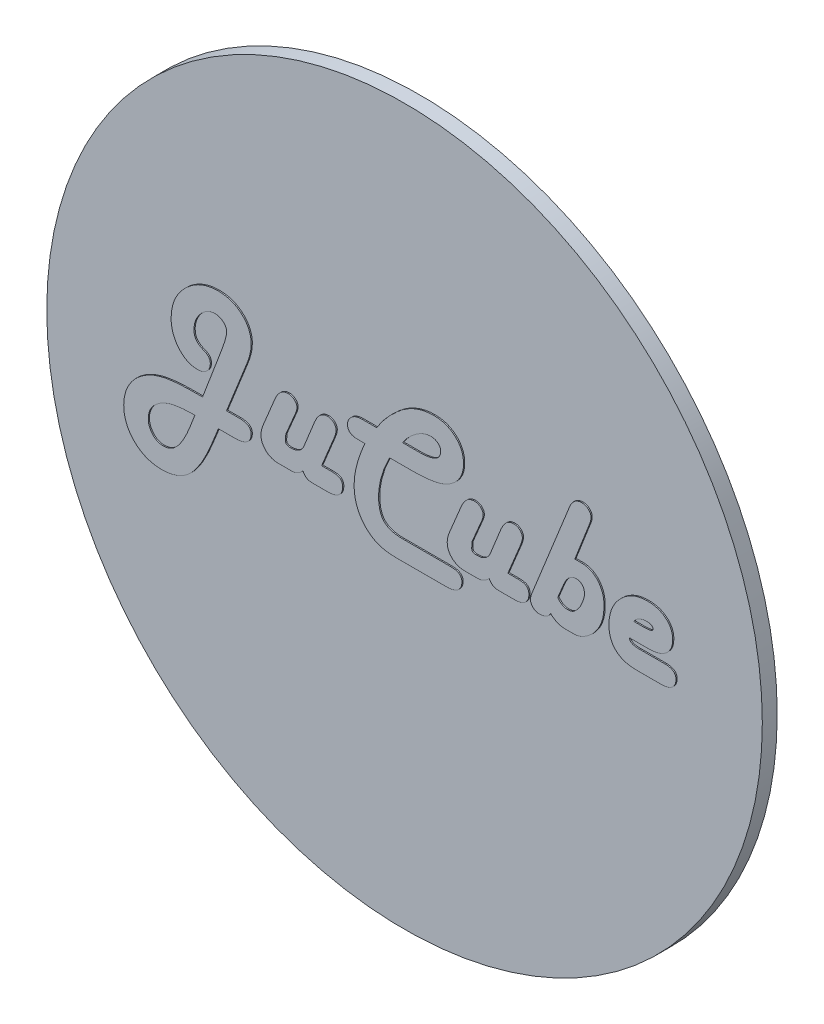
from build123d import *

# Parameters (mm, degrees)
SKETCH2_R           = 76.2
BOSS_EXTRUDE1_DEPTH = 3.175
BOSS_EXTRUDE2_DEPTH = 0.254


with BuildPart() as part:
    # Sketch2 → Boss-Extrude1 (new body)
    with BuildSketch(Plane.XY):
        Circle(SKETCH2_R)
    extrude(amount=BOSS_EXTRUDE1_DEPTH)

    # Sketch3 → Boss-Extrude2 (add)
    with BuildSketch(Plane.XY.offset(3.175)):
        with BuildLine():
            Line((-37.659123821, 0.761566628), (-34.929928615, 0.761566628))
            add(Edge.make_bspline(
                [(-34.929928615, 0.761566628), (-34.732000697, 0.757334956), (-34.361404649, 0.749411664), (-33.846895815, 0.666966717), (-33.405729695, 0.542819083), (-33.046187459, 0.349501415), (-32.75569756, 0.108226576), (-32.55494843, -0.198645015), (-32.429839223, -0.557474704), (-32.418629851, -0.815774235), (-32.412762519, -0.950976181)],
                knots=[0, 0, 0, 0, 0.000593217, 0.001110728, 0.001559605, 0.00196096, 0.002327158, 0.002679995, 0.003047924, 0.003452032, 0.003452032, 0.003452032, 0.003452032], degree=3))
            add(Edge.make_bspline(
                [(-32.412762519, -0.950976181), (-32.42185546, -1.133653216), (-32.439475455, -1.487638649), (-32.616251317, -1.98773381), (-32.906818969, -2.421872662), (-33.307274661, -2.784915129), (-33.806577268, -3.066016083), (-34.390629542, -3.273847797), (-35.063213752, -3.389069801), (-35.538399919, -3.405247137), (-35.788918341, -3.413775838)],
                knots=[0, 0, 0, 0, 0.000546376, 0.001058749, 0.001568404, 0.002099416, 0.002664514, 0.00327671, 0.003950678, 0.004702195, 0.004702195, 0.004702195, 0.004702195], degree=3))
            Line((-35.788918341, -3.413775838), (-39.38797656, -3.413775838))
            Line((-39.38797656, -3.413775838), (-40.758010807, -6.78993166))
            add(Edge.make_bspline(
                [(-40.758010807, -6.78993166), (-40.94094851, -7.24095224), (-41.294886851, -8.113563373), (-41.869771364, -9.355300485), (-42.444799767, -10.495661457), (-43.016801144, -11.541187209), (-43.610746434, -12.474231369), (-44.203680932, -13.310722851), (-44.797157232, -14.050084639), (-45.414039488, -14.681322226), (-46.047165869, -15.232128734), (-46.718304588, -15.697839826), (-47.421880148, -16.100513336), (-48.169538921, -16.420424934), (-48.950929595, -16.677623268), (-49.772431327, -16.856998146), (-50.630135408, -16.959859916), (-51.214213211, -16.975614711), (-51.511692314, -16.983638852)],
                knots=[0, 0, 0, 0, 0.001459949, 0.002824633, 0.004103528, 0.00529112, 0.006398182, 0.00741949, 0.008366231, 0.00923896, 0.010063934, 0.010879884, 0.011685718, 0.012491681, 0.013315203, 0.014150201, 0.015009982, 0.015902403, 0.015902403, 0.015902403, 0.015902403], degree=3))
            add(Edge.make_bspline(
                [(-51.511692314, -16.983638852), (-51.79300825, -16.978714749), (-52.345174208, -16.969049735), (-53.154106481, -16.853131777), (-53.928944651, -16.683452373), (-54.668070179, -16.435918773), (-55.372159073, -16.120931999), (-56.039539903, -15.730779636), (-56.67240655, -15.273070202), (-57.261460462, -14.747471473), (-57.796234402, -14.169862414), (-58.266123003, -13.552860262), (-58.668826651, -12.903400132), (-58.986814375, -12.212637489), (-59.246634448, -11.493794487), (-59.425865919, -10.73702721), (-59.528555794, -9.946030557), (-59.544423415, -9.407067287), (-59.552488547, -9.133125153)],
                knots=[0, 0, 0, 0, 0.000843311, 0.001655248, 0.002446611, 0.003220259, 0.003989213, 0.004756627, 0.005535264, 0.00632853, 0.00712105, 0.007893072, 0.008652064, 0.009408461, 0.010170232, 0.010941641, 0.011736694, 0.012558508, 0.012558508, 0.012558508, 0.012558508], degree=3))
            add(Edge.make_bspline(
                [(-59.552488547, -9.133125153), (-59.548557226, -8.924522998), (-59.540777556, -8.511721197), (-59.47110314, -7.900011899), (-59.370206804, -7.299917087), (-59.2222682, -6.711237158), (-59.03176017, -6.133297959), (-58.797185315, -5.569163223), (-58.524541113, -5.016100147), (-58.208277655, -4.4796688), (-57.857476424, -3.957803765), (-57.463078214, -3.461419005), (-57.032657956, -2.989230409), (-56.571103829, -2.537527223), (-56.074827024, -2.110707886), (-55.539272776, -1.716170474), (-54.973299911, -1.337080429), (-54.574019145, -1.109815875), (-54.371366971, -0.994469331)],
                knots=[0, 0, 0, 0, 0.000625592, 0.001237981, 0.001844868, 0.002450096, 0.003056982, 0.003668816, 0.004281519, 0.004905313, 0.005535612, 0.006166473, 0.006805366, 0.007451252, 0.008102856, 0.008767217, 0.009445753, 0.010145075, 0.010145075, 0.010145075, 0.010145075], degree=3))
            add(Edge.make_bspline(
                [(-54.371366971, -0.994469331), (-54.098172271, -0.85535278), (-53.538982224, -0.570601315), (-52.633366723, -0.228852468), (-51.659879349, 0.074069721), (-50.607504328, 0.30607127), (-49.485249233, 0.50073947), (-48.286298376, 0.624098713), (-47.013209798, 0.709671837), (-46.138632965, 0.71881168), (-45.689046766, 0.723510121)],
                knots=[0, 0, 0, 0, 0.000919098, 0.001881261, 0.002899323, 0.003975518, 0.005111516, 0.006314674, 0.007589459, 0.008938021, 0.008938021, 0.008938021, 0.008938021], degree=3))
            Line((-45.689046766, 0.723510121), (-42.764132382, 0.761566628))
            Line((-42.764132382, 0.761566628), (-38.681212862, 11.498938203))
            add(Edge.make_bspline(
                [(-38.681212862, 11.498938203), (-38.598756739, 11.723333537), (-38.441578026, 12.151078242), (-38.230742664, 12.768315854), (-38.041899513, 13.326004628), (-37.895868336, 13.832723373), (-37.780641924, 14.282258613), (-37.697760768, 14.67557985), (-37.643957976, 15.013162142), (-37.635692743, 15.221076126), (-37.631940601, 15.315462175)],
                knots=[0, 0, 0, 0, 0.000717163, 0.001367064, 0.001956758, 0.002483243, 0.002948704, 0.003348546, 0.003689151, 0.003972327, 0.003972327, 0.003972327, 0.003972327], degree=3))
            add(Edge.make_bspline(
                [(-37.631940601, 15.315462175), (-37.639061892, 15.45638358), (-37.65322501, 15.736653912), (-37.807150594, 16.136068021), (-38.038192881, 16.508539132), (-38.362768598, 16.834041558), (-38.73995381, 17.114611654), (-39.16764032, 17.31984482), (-39.631144023, 17.443435823), (-39.95262529, 17.456352671), (-40.116486834, 17.462936491)],
                knots=[0, 0, 0, 0, 0.000420875, 0.000837053, 0.001266961, 0.00172834, 0.002206795, 0.002671239, 0.00314332, 0.003634095, 0.003634095, 0.003634095, 0.003634095], degree=3))
            add(Edge.make_bspline(
                [(-40.116486834, 17.462936491), (-40.256386136, 17.457439369), (-40.534613385, 17.44650687), (-40.946931004, 17.366410861), (-41.350246588, 17.241597811), (-41.745321775, 17.066258696), (-42.128468099, 16.835804412), (-42.495975681, 16.548195864), (-42.864391924, 16.222560887), (-43.211295225, 15.845319681), (-43.530637762, 15.438564698), (-43.820177326, 15.019493951), (-44.049500327, 14.581571233), (-44.250893892, 14.139125425), (-44.402094466, 13.681358278), (-44.510381764, 13.213674485), (-44.578911039, 12.735077402), (-44.586833199, 12.412524734), (-44.590844711, 12.249195052)],
                knots=[0, 0, 0, 0, 0.000419503, 0.000834295, 0.001255591, 0.001683948, 0.00212776, 0.002593157, 0.003082122, 0.003601457, 0.004127886, 0.004633026, 0.005126804, 0.005608706, 0.006090087, 0.006570116, 0.007047582, 0.007537363, 0.007537363, 0.007537363, 0.007537363], degree=3))
            add(Edge.make_bspline(
                [(-44.590844711, 12.249195052), (-44.58462232, 12.080249628), (-44.572677658, 11.755937689), (-44.481626816, 11.296391877), (-44.326893813, 10.890538116), (-44.112382085, 10.527047415), (-43.800760714, 10.21748581), (-43.414353194, 9.928166457), (-42.939059556, 9.657183009), (-42.582920228, 9.507038097), (-42.394440601, 9.427576901)],
                knots=[0, 0, 0, 0, 0.000506659, 0.000972596, 0.001397663, 0.001805121, 0.002228063, 0.002705405, 0.003250942, 0.003864223, 0.003864223, 0.003864223, 0.003864223], degree=3))
            add(Edge.make_bspline(
                [(-42.394440601, 9.427576901), (-42.293523138, 9.382890746), (-42.098708391, 9.296626964), (-41.835779784, 9.131728034), (-41.611140187, 8.948308597), (-41.429682502, 8.743523317), (-41.281275578, 8.523022086), (-41.186996436, 8.275294676), (-41.124177662, 8.011713598), (-41.115708098, 7.829581334), (-41.111392656, 7.736780669)],
                knots=[0, 0, 0, 0, 0.000330743, 0.000638478, 0.000928053, 0.001197592, 0.00145696, 0.001720455, 0.001988179, 0.002266299, 0.002266299, 0.002266299, 0.002266299], degree=3))
            add(Edge.make_bspline(
                [(-41.111392656, 7.736780669), (-41.120557067, 7.569052784), (-41.138563291, 7.239501236), (-41.288608462, 6.766075357), (-41.550450915, 6.345763692), (-41.88976163, 5.970131542), (-42.309936774, 5.670460098), (-42.779841794, 5.439085007), (-43.304520572, 5.308699137), (-43.669552917, 5.292941541), (-43.856897793, 5.284854299)],
                knots=[0, 0, 0, 0, 0.000502559, 0.000987427, 0.001470402, 0.001978372, 0.002495996, 0.003009061, 0.003541769, 0.00410343, 0.00410343, 0.00410343, 0.00410343], degree=3))
            add(Edge.make_bspline(
                [(-43.856897793, 5.284854299), (-44.047484016, 5.291897574), (-44.423379813, 5.305789123), (-44.976962026, 5.392893029), (-45.509000964, 5.545156757), (-46.016130847, 5.768400552), (-46.508026459, 6.037449282), (-46.97460369, 6.376016848), (-47.420093542, 6.772050462), (-47.834507718, 7.229188406), (-48.216523508, 7.722260447), (-48.554017623, 8.247919439), (-48.826828784, 8.805729123), (-49.064366477, 9.381261758), (-49.245632105, 9.985677316), (-49.366995947, 10.616134606), (-49.446193159, 11.272229654), (-49.456721611, 11.717982197), (-49.462077588, 11.944742997)],
                knots=[0, 0, 0, 0, 0.000571779, 0.001127727, 0.001676613, 0.002227004, 0.002786741, 0.00335554, 0.003952408, 0.004571923, 0.005203721, 0.00582209, 0.006442082, 0.007063978, 0.00768834, 0.008331268, 0.00898809, 0.009668214, 0.009668214, 0.009668214, 0.009668214], degree=3))
            add(Edge.make_bspline(
                [(-49.462077588, 11.944742997), (-49.452587427, 12.276911868), (-49.433830958, 12.933414513), (-49.287109542, 13.900283343), (-49.056236528, 14.836500593), (-48.718238204, 15.735098271), (-48.303231371, 16.608152048), (-47.770667662, 17.434148158), (-47.161909593, 18.239085414), (-46.460942683, 18.996553097), (-45.694871557, 19.687923497), (-44.898152047, 20.312808211), (-44.052965895, 20.819851549), (-43.186129785, 21.253809479), (-42.276946979, 21.575705222), (-41.341485028, 21.820400483), (-40.368708145, 21.955830949), (-39.710938259, 21.975991943), (-39.377103273, 21.986224162)],
                knots=[0, 0, 0, 0, 0.000996108, 0.001968721, 0.002927329, 0.003883715, 0.004844172, 0.005821559, 0.006826279, 0.007868939, 0.008911939, 0.009919964, 0.010900852, 0.011863691, 0.012823317, 0.013788531, 0.014760368, 0.015761907, 0.015761907, 0.015761907, 0.015761907], degree=3))
            add(Edge.make_bspline(
                [(-39.377103273, 21.986224162), (-39.134000327, 21.981596116), (-38.655236172, 21.972481696), (-37.954886639, 21.883117548), (-37.284303269, 21.740036106), (-36.642953579, 21.54870973), (-36.03514958, 21.28809828), (-35.457302259, 20.978697391), (-34.909394183, 20.612802278), (-34.40209964, 20.18908062), (-33.937468484, 19.725591076), (-33.526673797, 19.230483202), (-33.181447142, 18.705634418), (-32.901630164, 18.150705375), (-32.684567981, 17.566868097), (-32.525484661, 16.955227434), (-32.431984314, 16.313246959), (-32.419256223, 15.875742885), (-32.412762519, 15.652534093)],
                knots=[0, 0, 0, 0, 0.000729017, 0.001435718, 0.002113884, 0.002784599, 0.003439934, 0.004094254, 0.004748665, 0.005412737, 0.006073954, 0.006715063, 0.007339331, 0.007954465, 0.008575505, 0.00920449, 0.009847257, 0.010516759, 0.010516759, 0.010516759, 0.010516759], degree=3))
            add(Edge.make_bspline(
                [(-32.412762519, 15.652534093), (-32.425495868, 15.349140537), (-32.452302054, 14.710437853), (-32.646754358, 13.712877307), (-32.953221742, 12.630854172), (-33.229852759, 11.892116925), (-33.375048478, 11.504374847)],
                knots=[0, 0, 0, 0, 0.000909887, 0.00191549, 0.003039403, 0.004280983, 0.004280983, 0.004280983, 0.004280983], degree=3))
            Line((-33.375048478, 11.504374847), (-37.659123821, 0.761566628))
        make_face()
        with BuildLine():
            add(Edge.make_bspline(
                [(-44.395125533, -3.413775838), (-44.705074548, -3.415003178), (-45.305291902, -3.417379925), (-46.176992632, -3.460045186), (-46.993365688, -3.509813747), (-47.755469849, -3.590222225), (-48.460148251, -3.700960011), (-49.111041158, -3.822360629), (-49.705036818, -3.973094901), (-50.077095438, -4.09840074), (-50.255827588, -4.158596044)],
                knots=[0, 0, 0, 0, 0.00092973, 0.001800425, 0.002617732, 0.003383218, 0.004098297, 0.004757231, 0.005369064, 0.005934711, 0.005934711, 0.005934711, 0.005934711], degree=3))
            add(Edge.make_bspline(
                [(-50.255827588, -4.158596044), (-50.558633441, -4.27737887), (-51.14685462, -4.508122674), (-51.944648442, -4.97939686), (-52.650479214, -5.513057415), (-53.24866713, -6.120430548), (-53.730586186, -6.782596729), (-54.082514748, -7.488317528), (-54.289989603, -8.233505129), (-54.318848794, -8.742264106), (-54.333310464, -8.997209057)],
                knots=[0, 0, 0, 0, 0.000974434, 0.001892905, 0.002769335, 0.003622802, 0.004440615, 0.005216228, 0.005977241, 0.006741646, 0.006741646, 0.006741646, 0.006741646], degree=3))
            add(Edge.make_bspline(
                [(-54.333310464, -8.997209057), (-54.322141361, -9.230341707), (-54.30034302, -9.685338377), (-54.119867612, -10.338875048), (-53.827246354, -10.936765406), (-53.426355094, -11.466056406), (-52.941205018, -11.907230569), (-52.389742586, -12.229237185), (-51.783419024, -12.423088576), (-51.362687572, -12.447739515), (-51.147437177, -12.460351181)],
                knots=[0, 0, 0, 0, 0.000698455, 0.00136315, 0.002017199, 0.002684823, 0.003343106, 0.003971597, 0.004587163, 0.005231996, 0.005231996, 0.005231996, 0.005231996], degree=3))
            add(Edge.make_bspline(
                [(-51.147437177, -12.460351181), (-51.007589047, -12.456641007), (-50.729680248, -12.449268081), (-50.318942175, -12.375442306), (-49.919038893, -12.255841829), (-49.532239371, -12.084338655), (-49.15382751, -11.87164496), (-48.788243334, -11.608185192), (-48.435872758, -11.296212865), (-48.089421437, -10.939078439), (-47.751402392, -10.526900427), (-47.416216742, -10.058625109), (-47.079933018, -9.535430332), (-46.741125795, -8.958543339), (-46.411262934, -8.319787469), (-46.081682699, -7.624397943), (-45.747139206, -6.873896427), (-45.540220694, -6.34859803), (-45.433524505, -6.077731318)],
                knots=[0, 0, 0, 0, 0.000419186, 0.000833014, 0.00124752, 0.001668711, 0.002099615, 0.002547701, 0.003017711, 0.00350984, 0.004038873, 0.00461526, 0.005236562, 0.005904185, 0.006621534, 0.007392407, 0.008212692, 0.009085963, 0.009085963, 0.009085963, 0.009085963], degree=3))
            Line((-45.433524505, -6.077731318), (-44.395125533, -3.413775838))
        make_face(mode=Mode.SUBTRACT)
        with BuildLine():
            Line((-17.402188889, 0.761566628), (-15.276461149, 0.761566628))
            add(Edge.make_bspline(
                [(-15.276461149, 0.761566628), (-15.078578303, 0.759287218), (-14.711865945, 0.755063063), (-14.210098024, 0.678471534), (-13.794956786, 0.56519082), (-13.465404173, 0.390089382), (-13.218658697, 0.149192289), (-13.044991842, -0.152789123), (-12.94229572, -0.518608252), (-12.932837387, -0.783554627), (-12.927831012, -0.923792962)],
                knots=[0, 0, 0, 0, 0.000592993, 0.001098922, 0.001518637, 0.001878771, 0.002205558, 0.00253937, 0.002912761, 0.003332651, 0.003332651, 0.003332651, 0.003332651], degree=3))
            add(Edge.make_bspline(
                [(-12.927831012, -0.923792962), (-12.935221105, -1.109987413), (-12.949435509, -1.468121329), (-13.114997405, -1.969958778), (-13.376900736, -2.408404023), (-13.742732008, -2.776765929), (-14.20278672, -3.065743584), (-14.747055486, -3.273981391), (-15.373204983, -3.388649654), (-15.816040525, -3.405127417), (-16.048464574, -3.413775838)],
                knots=[0, 0, 0, 0, 0.000556692, 0.001070764, 0.001565857, 0.002077162, 0.002612554, 0.003183997, 0.003815209, 0.004512458, 0.004512458, 0.004512458, 0.004512458], degree=3))
            Line((-16.048464574, -3.413775838), (-19.332197451, -3.413775838))
            add(Edge.make_bspline(
                [(-19.332197451, -3.413775838), (-19.455599112, -3.408919917), (-19.692771483, -3.399587057), (-20.033757818, -3.347628606), (-20.342914078, -3.250175465), (-20.616126042, -3.10638804), (-20.860154508, -2.929348914), (-21.076613243, -2.716848765), (-21.250632979, -2.454977429), (-21.340809122, -2.262481165), (-21.387248821, -2.163347756)],
                knots=[0, 0, 0, 0, 0.000370331, 0.000711759, 0.001031552, 0.00133794, 0.001633725, 0.001933579, 0.002242704, 0.002570935, 0.002570935, 0.002570935, 0.002570935], degree=3))
            add(Edge.make_bspline(
                [(-21.387248821, -2.163347756), (-21.472587497, -2.262694357), (-21.638980275, -2.456399692), (-21.911728134, -2.716719326), (-22.208081153, -2.929265375), (-22.519938645, -3.101747599), (-22.842832813, -3.249043311), (-23.185761806, -3.344901419), (-23.545665038, -3.399401489), (-23.790056511, -3.408905678), (-23.915288204, -3.413775838)],
                knots=[0, 0, 0, 0, 0.000392795, 0.000765869, 0.001128009, 0.001483392, 0.001833919, 0.002190133, 0.002547672, 0.002923431, 0.002923431, 0.002923431, 0.002923431], degree=3))
            Line((-23.915288204, -3.413775838), (-26.595553615, -3.413775838))
            add(Edge.make_bspline(
                [(-26.595553615, -3.413775838), (-26.854136996, -3.40373138), (-27.354927273, -3.384278594), (-28.068965822, -3.192492526), (-28.714734722, -2.883683873), (-29.278811693, -2.454373797), (-29.741191577, -1.928805376), (-30.082735254, -1.3267446), (-30.291503261, -0.656414877), (-30.313723352, -0.185910159), (-30.325091286, 0.054802929)],
                knots=[0, 0, 0, 0, 0.000774316, 0.001499594, 0.002199888, 0.002909927, 0.003611106, 0.004285447, 0.004973349, 0.005693946, 0.005693946, 0.005693946, 0.005693946], degree=3))
            add(Edge.make_bspline(
                [(-30.325091286, 0.054802929), (-30.320183157, 0.203868212), (-30.309861657, 0.517343551), (-30.207044792, 1.000354574), (-30.062153222, 1.52135069), (-29.92435149, 1.871767473), (-29.852103273, 2.05548786)],
                knots=[0, 0, 0, 0, 0.000446633, 0.000939242, 0.001476178, 0.002067948, 0.002067948, 0.002067948, 0.002067948], degree=3))
            Line((-29.852103273, 2.05548786), (-27.378430327, 8.019486148))
            add(Edge.make_bspline(
                [(-27.378430327, 8.019486148), (-27.291343221, 8.215130561), (-27.12495941, 8.588917962), (-26.831696188, 9.096498409), (-26.514209176, 9.530686056), (-26.167619107, 9.883164517), (-25.79916583, 10.166399162), (-25.399603916, 10.355176183), (-24.979886333, 10.48522119), (-24.688285534, 10.497705389), (-24.540502245, 10.504032381)],
                knots=[0, 0, 0, 0, 0.0006421, 0.00122676, 0.001755206, 0.002251134, 0.002705639, 0.003140876, 0.003571024, 0.004013034, 0.004013034, 0.004013034, 0.004013034], degree=3))
            add(Edge.make_bspline(
                [(-24.540502245, 10.504032381), (-24.414712081, 10.500316255), (-24.170273167, 10.493094976), (-23.822002511, 10.393072152), (-23.498034297, 10.247385068), (-23.216416608, 10.034735634), (-22.974919214, 9.787854991), (-22.795924864, 9.505764685), (-22.686661485, 9.192475462), (-22.675816478, 8.973577172), (-22.670296766, 8.862165943)],
                knots=[0, 0, 0, 0, 0.000376112, 0.000730871, 0.001078689, 0.001436435, 0.001782506, 0.002109836, 0.002431334, 0.00276457, 0.00276457, 0.00276457, 0.00276457], degree=3))
            add(Edge.make_bspline(
                [(-22.670296766, 8.862165943), (-22.673389943, 8.77312266), (-22.67988147, 8.586251078), (-22.738962214, 8.296593203), (-22.831453357, 7.987869131), (-22.915034983, 7.779662543), (-22.958438889, 7.671540943)],
                knots=[0, 0, 0, 0, 0.000266894, 0.000560121, 0.000883498, 0.001232842, 0.001232842, 0.001232842, 0.001232842], degree=3))
            Line((-22.958438889, 7.671540943), (-23.154158067, 7.209426217))
            Line((-23.154158067, 7.209426217), (-25.035236834, 2.773124847))
            Line((-25.035236834, 2.773124847), (-25.073293341, 2.245770395))
            add(Edge.make_bspline(
                [(-25.073293341, 2.245770395), (-25.081178842, 2.11169573), (-25.094707848, 1.88166635), (-25.102614863, 1.651378967), (-25.105913204, 1.555316628)],
                knots=[0, 0, 0, 0, 0.000402899, 0.000691246, 0.000691246, 0.000691246, 0.000691246], degree=3))
            add(Edge.make_bspline(
                [(-25.105913204, 1.555316628), (-25.107194276, 1.493390257), (-25.109644699, 1.374937988), (-25.064268859, 1.209238698), (-24.987670306, 1.06541288), (-24.866391769, 0.955305125), (-24.716159452, 0.867846174), (-24.534064094, 0.802716092), (-24.317305095, 0.765289511), (-24.161908737, 0.76286808), (-24.078387519, 0.761566628)],
                knots=[0, 0, 0, 0, 0.000184926, 0.000353725, 0.000509501, 0.000667164, 0.000837791, 0.001028694, 0.001244112, 0.001494434, 0.001494434, 0.001494434, 0.001494434], degree=3))
            add(Edge.make_bspline(
                [(-24.078387519, 0.761566628), (-23.902305477, 0.766534326), (-23.562602324, 0.776118169), (-23.075210855, 0.856228085), (-22.635458897, 0.99782624), (-22.242624404, 1.195851496), (-21.895415476, 1.449224083), (-21.593282578, 1.75684915), (-21.337569223, 2.122678164), (-21.212571269, 2.397475143), (-21.148036492, 2.539349162)],
                knots=[0, 0, 0, 0, 0.000528055, 0.00101874, 0.001476065, 0.00190885, 0.002332943, 0.002759677, 0.003197048, 0.003663872, 0.003663872, 0.003663872, 0.003663872], degree=3))
            Line((-21.148036492, 2.539349162), (-18.929885807, 8.014049504))
            add(Edge.make_bspline(
                [(-18.929885807, 8.014049504), (-18.84621791, 8.209482286), (-18.686532185, 8.582478697), (-18.404783727, 9.094823181), (-18.088286848, 9.526086488), (-17.751813855, 9.884488135), (-17.387631718, 10.167554912), (-16.98904609, 10.355037708), (-16.569416246, 10.485256749), (-16.27780355, 10.497717349), (-16.130014232, 10.504032381)],
                knots=[0, 0, 0, 0, 0.000637573, 0.001216849, 0.001749668, 0.002238029, 0.002688188, 0.003123426, 0.003553574, 0.003995583, 0.003995583, 0.003995583, 0.003995583], degree=3))
            add(Edge.make_bspline(
                [(-16.130014232, 10.504032381), (-16.009779936, 10.497700741), (-15.77465904, 10.485319077), (-15.434273271, 10.389013064), (-15.121946532, 10.230411583), (-14.846267094, 10.011294266), (-14.614385056, 9.755099803), (-14.43877245, 9.467192927), (-14.337414623, 9.147847423), (-14.325627056, 8.926294898), (-14.319611834, 8.813236148)],
                knots=[0, 0, 0, 0, 0.000360298, 0.000704571, 0.001052262, 0.001404638, 0.001754996, 0.002084126, 0.002409099, 0.002747746, 0.002747746, 0.002747746, 0.002747746], degree=3))
            add(Edge.make_bspline(
                [(-14.319611834, 8.813236148), (-14.325848123, 8.707739888), (-14.339985554, 8.468583853), (-14.436658831, 8.07782782), (-14.585909584, 7.612103966), (-14.71614142, 7.281168578), (-14.787163204, 7.10069334)],
                knots=[0, 0, 0, 0, 0.000316495, 0.000717482, 0.00120235, 0.001783944, 0.001783944, 0.001783944, 0.001783944], degree=3))
            Line((-14.787163204, 7.10069334), (-17.402188889, 0.761566628))
        make_face()
        with BuildLine():
            add(Edge.make_bspline(
                [(-2.924406355, 9.460196764), (-3.110888384, 9.086710906), (-3.476506858, 8.354450914), (-3.955560957, 7.250065392), (-4.359505456, 6.16460287), (-4.692647162, 5.101744473), (-4.949658865, 4.057524819), (-5.13678633, 3.033992717), (-5.248494977, 2.028980833), (-5.264944955, 1.365294447), (-5.273036492, 1.038835463)],
                knots=[0, 0, 0, 0, 0.0012522, 0.002455075, 0.003609347, 0.004725343, 0.005794719, 0.006833388, 0.007845028, 0.008824363, 0.008824363, 0.008824363, 0.008824363], degree=3))
            add(Edge.make_bspline(
                [(-5.273036492, 1.038835463), (-5.271136197, 0.817577207), (-5.267452508, 0.388671957), (-5.204503622, -0.228553641), (-5.114285604, -0.799539831), (-4.987251381, -1.321395079), (-4.814644625, -1.792667656), (-4.619882919, -2.221944793), (-4.368223515, -2.592898803), (-4.092388005, -2.92683126), (-3.76060235, -3.208424107), (-3.38685358, -3.452882751), (-2.959265794, -3.654447302), (-2.487515364, -3.821322226), (-1.965185908, -3.952756363), (-1.39356115, -4.040305822), (-0.772933043, -4.104437526), (-0.342184724, -4.107882224), (-0.119098136, -4.109666249)],
                knots=[0, 0, 0, 0, 0.000663471, 0.001286127, 0.001859042, 0.002397023, 0.002894022, 0.003363372, 0.003806683, 0.0042348, 0.004658788, 0.005106644, 0.005571087, 0.006073204, 0.006605912, 0.007184193, 0.007806849, 0.008475755, 0.008475755, 0.008475755, 0.008475755], degree=3))
            Line((-0.119098136, -4.109666249), (10.085482344, -4.109666249))
            add(Edge.make_bspline(
                [(10.085482344, -4.109666249), (10.27247775, -4.114438186), (10.622846194, -4.123379241), (11.112189896, -4.199732072), (11.530644038, -4.317683534), (11.875246982, -4.500226608), (12.14338358, -4.739413007), (12.341867466, -5.028728981), (12.452020157, -5.376200233), (12.465220618, -5.622098446), (12.472168988, -5.751532688)],
                knots=[0, 0, 0, 0, 0.000560634, 0.001050445, 0.001482136, 0.00185919, 0.002209548, 0.002550326, 0.002899332, 0.003287205, 0.003287205, 0.003287205, 0.003287205], degree=3))
            add(Edge.make_bspline(
                [(12.472168988, -5.751532688), (12.46252124, -5.94126782), (12.444054089, -6.304447648), (12.280079466, -6.817568915), (12.007529634, -7.26483141), (11.623475233, -7.6364588), (11.146756495, -7.935758573), (10.576621138, -8.136246746), (9.926125438, -8.262913528), (9.464554983, -8.27737804), (9.221055974, -8.285008715)],
                knots=[0, 0, 0, 0, 0.000568019, 0.001087268, 0.001597299, 0.002123981, 0.002676061, 0.003272929, 0.003926526, 0.004656334, 0.004656334, 0.004656334, 0.004656334], degree=3))
            Line((9.221055974, -8.285008715), (-1.418456012, -8.285008715))
            add(Edge.make_bspline(
                [(-1.418456012, -8.285008715), (-1.636003908, -8.283716044), (-2.060582799, -8.281193194), (-2.680391743, -8.238519379), (-3.268677726, -8.188364892), (-3.822820204, -8.108508382), (-4.341871445, -7.995206227), (-4.830753767, -7.875832175), (-5.284593739, -7.722791989), (-5.569179565, -7.600048669), (-5.707967999, -7.540188509)],
                knots=[0, 0, 0, 0, 0.000652488, 0.001273433, 0.001863102, 0.002423604, 0.002951406, 0.003456429, 0.003932656, 0.004385988, 0.004385988, 0.004385988, 0.004385988], degree=3))
            add(Edge.make_bspline(
                [(-5.707967999, -7.540188509), (-5.890673412, -7.450535051), (-6.252304324, -7.273082938), (-6.766310714, -6.959470252), (-7.252176256, -6.61120221), (-7.705902291, -6.224989468), (-8.135105783, -5.810918503), (-8.527145658, -5.355925722), (-8.890406948, -4.865933829), (-9.227302686, -4.346334253), (-9.5274127, -3.798272314), (-9.778553936, -3.224273952), (-10.008843038, -2.638266699), (-10.1757898, -2.025805205), (-10.322208765, -1.401356909), (-10.417091309, -0.7557267), (-10.479145647, -0.091391231), (-10.487816767, 0.359109644), (-10.492214574, 0.587594025)],
                knots=[0, 0, 0, 0, 0.000610286, 0.001207946, 0.001803922, 0.002401879, 0.002993949, 0.003591312, 0.004201308, 0.004822609, 0.005447847, 0.006073274, 0.006701318, 0.007334588, 0.007975582, 0.008624526, 0.009290488, 0.00997585, 0.00997585, 0.00997585, 0.00997585], degree=3))
            add(Edge.make_bspline(
                [(-10.492214574, 0.587594025), (-10.48363573, 0.904967936), (-10.46604485, 1.555741661), (-10.359011649, 2.554944788), (-10.179155014, 3.599050291), (-9.918020648, 4.685786687), (-9.599688951, 5.819696127), (-9.196937671, 6.994554692), (-8.732004153, 8.218040744), (-8.375300766, 9.039337384), (-8.192514232, 9.460196764)],
                knots=[0, 0, 0, 0, 0.000952173, 0.001952427, 0.003011569, 0.004128518, 0.005303952, 0.006543519, 0.007853073, 0.009229414, 0.009229414, 0.009229414, 0.009229414], degree=3))
            Line((-8.192514232, 9.460196764), (-9.220039916, 9.460196764))
            Line((-9.220039916, 9.460196764), (-9.698464574, 9.460196764))
            add(Edge.make_bspline(
                [(-9.698464574, 9.460196764), (-9.869109387, 9.465297169), (-10.19055539, 9.474904872), (-10.639976897, 9.548003234), (-11.023759339, 9.675490137), (-11.336962614, 9.864015828), (-11.586218951, 10.103795428), (-11.764275315, 10.401285901), (-11.868912077, 10.752737596), (-11.878813496, 11.003465046), (-11.883995396, 11.134683066)],
                knots=[0, 0, 0, 0, 0.000511767, 0.000964023, 0.001361195, 0.001717368, 0.002051843, 0.002388433, 0.002746179, 0.003138974, 0.003138974, 0.003138974, 0.003138974], degree=3))
            add(Edge.make_bspline(
                [(-11.883995396, 11.134683066), (-11.8748013, 11.304910985), (-11.856713847, 11.639798654), (-11.673665644, 12.11376547), (-11.397889385, 12.549982887), (-11.005557942, 12.92349703), (-10.545526371, 13.243597156), (-10.020867736, 13.472559664), (-9.450386702, 13.614079989), (-9.05416978, 13.628249936), (-8.850348136, 13.63553923)],
                knots=[0, 0, 0, 0, 0.000508522, 0.001000411, 0.001504115, 0.002046174, 0.002613177, 0.003177882, 0.003754114, 0.00436457, 0.00436457, 0.00436457, 0.00436457], degree=3))
            Line((-8.850348136, 13.63553923), (-8.355613547, 13.63553923))
            Line((-8.355613547, 13.63553923), (-5.697094711, 13.63553923))
            add(Edge.make_bspline(
                [(-5.697094711, 13.63553923), (-5.403785954, 14.086735299), (-4.804549838, 15.008538601), (-3.742901028, 16.316556166), (-2.559206694, 17.61571328), (-1.678706018, 18.424545825), (-1.228173478, 18.838407381)],
                knots=[0, 0, 0, 0, 0.001613429, 0.00329627, 0.005046945, 0.006881351, 0.006881351, 0.006881351, 0.006881351], degree=3))
            add(Edge.make_bspline(
                [(-1.228173478, 18.838407381), (-0.931742381, 19.090556883), (-0.350243436, 19.585190106), (0.582125021, 20.217773348), (1.520816219, 20.76863814), (2.485952892, 21.209333095), (3.464684337, 21.562353718), (4.465506533, 21.805060808), (5.481316469, 21.95844099), (6.165121646, 21.976942425), (6.5081707, 21.986224162)],
                knots=[0, 0, 0, 0, 0.001166689, 0.002288655, 0.003375018, 0.004428339, 0.005466951, 0.006491496, 0.00751331, 0.008542, 0.008542, 0.008542, 0.008542], degree=3))
            add(Edge.make_bspline(
                [(6.5081707, 21.986224162), (6.731299119, 21.980860095), (7.168009311, 21.970361465), (7.808131944, 21.892232415), (8.419238158, 21.767539548), (9.003226403, 21.595508864), (9.556943634, 21.365147327), (10.077325543, 21.080955547), (10.5730231, 20.753097645), (11.030636945, 20.374387766), (11.447977382, 19.957981222), (11.81691781, 19.509824864), (12.124967735, 19.03005179), (12.386053254, 18.52621531), (12.581968614, 17.99065202), (12.714013195, 17.426124682), (12.807206337, 16.837161128), (12.815761136, 16.433976422), (12.820114193, 16.22881834)],
                knots=[0, 0, 0, 0, 0.000669259, 0.001309884, 0.001931495, 0.002538674, 0.003133359, 0.003726925, 0.004314988, 0.004913636, 0.005505656, 0.006081351, 0.006651369, 0.00721303, 0.007780632, 0.008356865, 0.008950431, 0.009565373, 0.009565373, 0.009565373, 0.009565373], degree=3))
            add(Edge.make_bspline(
                [(12.820114193, 16.22881834), (12.810201738, 15.938074041), (12.790830777, 15.369900284), (12.623579342, 14.545458569), (12.348480229, 13.775877585), (11.97009967, 13.053644751), (11.476831636, 12.386301429), (10.867814802, 11.781800368), (10.161378506, 11.218057488), (9.627762942, 10.905197509), (9.351535426, 10.74324471)],
                knots=[0, 0, 0, 0, 0.00087156, 0.001703207, 0.002511422, 0.003316376, 0.004140597, 0.004990193, 0.005884269, 0.006843787, 0.006843787, 0.006843787, 0.006843787], degree=3))
            add(Edge.make_bspline(
                [(9.351535426, 10.74324471), (9.143158925, 10.639352619), (8.70680151, 10.421794095), (7.981477559, 10.166608911), (7.173219299, 9.944473897), (6.276793964, 9.76874021), (5.297171783, 9.626831697), (4.229873735, 9.533357736), (3.07654212, 9.472571455), (2.278546502, 9.464418865), (1.865276864, 9.460196764)],
                knots=[0, 0, 0, 0, 0.000697947, 0.001461559, 0.002301727, 0.003211208, 0.00419996, 0.005270026, 0.006424145, 0.007663891, 0.007663891, 0.007663891, 0.007663891], degree=3))
            Line((1.865276864, 9.460196764), (-2.924406355, 9.460196764))
        make_face()
        with BuildLine():
            Line((-0.189774505, 13.63553923), (3.365790563, 13.63553923))
            add(Edge.make_bspline(
                [(3.365790563, 13.63553923), (3.550651615, 13.638111212), (3.909701882, 13.643106696), (4.428793049, 13.667560396), (4.912637792, 13.719318816), (5.361823051, 13.780292631), (5.775058914, 13.869060178), (6.152741592, 13.969025972), (6.491477377, 14.096433918), (6.798812001, 14.236352841), (7.070256092, 14.396823906), (7.303593071, 14.581949577), (7.505755392, 14.778735054), (7.66654724, 15.002635631), (7.791277752, 15.243001328), (7.886179314, 15.50171057), (7.941011886, 15.780694901), (7.946223575, 15.973058409), (7.948881316, 16.071155669)],
                knots=[0, 0, 0, 0, 0.000554644, 0.001077269, 0.00155819, 0.002014123, 0.002436365, 0.002825456, 0.003184974, 0.00352064, 0.003837648, 0.004128038, 0.004412515, 0.00468112, 0.004951043, 0.005222766, 0.005505315, 0.005799347, 0.005799347, 0.005799347, 0.005799347], degree=3))
            add(Edge.make_bspline(
                [(7.948881316, 16.071155669), (7.941376162, 16.193295066), (7.926718987, 16.431826921), (7.816625985, 16.774748092), (7.616654252, 17.073052573), (7.355334154, 17.33548939), (7.032436898, 17.543099167), (6.671457086, 17.706893205), (6.263603493, 17.790790627), (5.981136756, 17.804001445), (5.834026864, 17.810881696)],
                knots=[0, 0, 0, 0, 0.000366238, 0.000715243, 0.001065095, 0.001434146, 0.001818652, 0.002210581, 0.002616877, 0.003058451, 0.003058451, 0.003058451, 0.003058451], degree=3))
            add(Edge.make_bspline(
                [(5.834026864, 17.810881696), (5.591582309, 17.796429224), (5.090711252, 17.766571572), (4.3326581, 17.53656606), (3.554596873, 17.170622559), (2.757120444, 16.6761857), (1.965322429, 16.065509616), (1.202489164, 15.34861814), (0.47683031, 14.535458788), (0.035766814, 13.940021045), (-0.189774505, 13.63553923)],
                knots=[0, 0, 0, 0, 0.00072652, 0.001500931, 0.002357181, 0.003301734, 0.004309759, 0.005352135, 0.006437968, 0.007574279, 0.007574279, 0.007574279, 0.007574279], degree=3))
        make_face(mode=Mode.SUBTRACT)
        with BuildLine():
            Line((22.263564536, 0.761566628), (24.389292275, 0.761566628))
            add(Edge.make_bspline(
                [(24.389292275, 0.761566628), (24.587175122, 0.759287218), (24.95388748, 0.755063063), (25.455655401, 0.678471534), (25.870796639, 0.56519082), (26.200349252, 0.390089382), (26.447094728, 0.149192289), (26.620761583, -0.152789123), (26.723457704, -0.518608252), (26.732916038, -0.783554627), (26.737922412, -0.923792962)],
                knots=[0, 0, 0, 0, 0.000592993, 0.001098922, 0.001518637, 0.001878771, 0.002205558, 0.00253937, 0.002912761, 0.003332651, 0.003332651, 0.003332651, 0.003332651], degree=3))
            add(Edge.make_bspline(
                [(26.737922412, -0.923792962), (26.730532319, -1.109987413), (26.716317916, -1.468121329), (26.55075602, -1.969958778), (26.288852689, -2.408404023), (25.923021417, -2.776765929), (25.462966705, -3.065743584), (24.918697938, -3.273981391), (24.292548441, -3.388649654), (23.849712899, -3.405127417), (23.617288851, -3.413775838)],
                knots=[0, 0, 0, 0, 0.000556692, 0.001070764, 0.001565857, 0.002077162, 0.002612554, 0.003183997, 0.003815209, 0.004512458, 0.004512458, 0.004512458, 0.004512458], degree=3))
            Line((23.617288851, -3.413775838), (20.333555974, -3.413775838))
            add(Edge.make_bspline(
                [(20.333555974, -3.413775838), (20.210154313, -3.408919917), (19.972981941, -3.399587057), (19.631995607, -3.347628606), (19.322839347, -3.250175465), (19.049627383, -3.10638804), (18.805598916, -2.929348914), (18.589140182, -2.716848765), (18.415120445, -2.454977429), (18.324944302, -2.262481165), (18.278504604, -2.163347756)],
                knots=[0, 0, 0, 0, 0.000370331, 0.000711759, 0.001031552, 0.00133794, 0.001633725, 0.001933579, 0.002242704, 0.002570935, 0.002570935, 0.002570935, 0.002570935], degree=3))
            add(Edge.make_bspline(
                [(18.278504604, -2.163347756), (18.193165928, -2.262694357), (18.026773149, -2.456399692), (17.75402529, -2.716719326), (17.457672272, -2.929265375), (17.145814779, -3.101747599), (16.822920611, -3.249043311), (16.479991619, -3.344901419), (16.120088387, -3.399401489), (15.875696914, -3.408905678), (15.750465221, -3.413775838)],
                knots=[0, 0, 0, 0, 0.000392795, 0.000765869, 0.001128009, 0.001483392, 0.001833919, 0.002190133, 0.002547672, 0.002923431, 0.002923431, 0.002923431, 0.002923431], degree=3))
            Line((15.750465221, -3.413775838), (13.07019981, -3.413775838))
            add(Edge.make_bspline(
                [(13.07019981, -3.413775838), (12.811616428, -3.40373138), (12.310826151, -3.384278594), (11.596787603, -3.192492526), (10.951018703, -2.883683873), (10.386941731, -2.454373797), (9.924561847, -1.928805376), (9.58301817, -1.3267446), (9.374250164, -0.656414877), (9.352030073, -0.185910159), (9.340662138, 0.054802929)],
                knots=[0, 0, 0, 0, 0.000774316, 0.001499594, 0.002199888, 0.002909927, 0.003611106, 0.004285447, 0.004973349, 0.005693946, 0.005693946, 0.005693946, 0.005693946], degree=3))
            add(Edge.make_bspline(
                [(9.340662138, 0.054802929), (9.345570267, 0.203868212), (9.355891768, 0.517343551), (9.458708633, 1.000354574), (9.603600203, 1.52135069), (9.741401935, 1.871767473), (9.813650152, 2.05548786)],
                knots=[0, 0, 0, 0, 0.000446633, 0.000939242, 0.001476178, 0.002067948, 0.002067948, 0.002067948, 0.002067948], degree=3))
            Line((9.813650152, 2.05548786), (12.287323097, 8.019486148))
            add(Edge.make_bspline(
                [(12.287323097, 8.019486148), (12.374410204, 8.215130561), (12.540794015, 8.588917962), (12.834057236, 9.096498409), (13.151544248, 9.530686056), (13.498134318, 9.883164517), (13.866587595, 10.166399162), (14.266149509, 10.355176183), (14.685867092, 10.48522119), (14.977467891, 10.497705389), (15.125251179, 10.504032381)],
                knots=[0, 0, 0, 0, 0.0006421, 0.00122676, 0.001755206, 0.002251134, 0.002705639, 0.003140876, 0.003571024, 0.004013034, 0.004013034, 0.004013034, 0.004013034], degree=3))
            add(Edge.make_bspline(
                [(15.125251179, 10.504032381), (15.251041344, 10.500316255), (15.495480258, 10.493094976), (15.843750913, 10.393072152), (16.167719128, 10.247385068), (16.449336817, 10.034735634), (16.69083421, 9.787854991), (16.86982856, 9.505764685), (16.979091939, 9.192475462), (16.989936947, 8.973577172), (16.995456659, 8.862165943)],
                knots=[0, 0, 0, 0, 0.000376112, 0.000730871, 0.001078689, 0.001436435, 0.001782506, 0.002109836, 0.002431334, 0.00276457, 0.00276457, 0.00276457, 0.00276457], degree=3))
            add(Edge.make_bspline(
                [(16.995456659, 8.862165943), (16.992363482, 8.77312266), (16.985871955, 8.586251078), (16.926791211, 8.296593203), (16.834300068, 7.987869131), (16.750718442, 7.779662543), (16.707314536, 7.671540943)],
                knots=[0, 0, 0, 0, 0.000266894, 0.000560121, 0.000883498, 0.001232842, 0.001232842, 0.001232842, 0.001232842], degree=3))
            Line((16.707314536, 7.671540943), (16.511595358, 7.209426217))
            Line((16.511595358, 7.209426217), (14.63051659, 2.773124847))
            Line((14.63051659, 2.773124847), (14.592460084, 2.245770395))
            add(Edge.make_bspline(
                [(14.592460084, 2.245770395), (14.584574583, 2.11169573), (14.571045577, 1.88166635), (14.563138562, 1.651378967), (14.559840221, 1.555316628)],
                knots=[0, 0, 0, 0, 0.000402899, 0.000691246, 0.000691246, 0.000691246, 0.000691246], degree=3))
            add(Edge.make_bspline(
                [(14.559840221, 1.555316628), (14.558559149, 1.493390257), (14.556108726, 1.374937988), (14.601484566, 1.209238698), (14.678083119, 1.06541288), (14.799361656, 0.955305125), (14.949593972, 0.867846174), (15.131689331, 0.802716092), (15.348448329, 0.765289511), (15.503844688, 0.76286808), (15.587365905, 0.761566628)],
                knots=[0, 0, 0, 0, 0.000184926, 0.000353725, 0.000509501, 0.000667164, 0.000837791, 0.001028694, 0.001244112, 0.001494434, 0.001494434, 0.001494434, 0.001494434], degree=3))
            add(Edge.make_bspline(
                [(15.587365905, 0.761566628), (15.763447948, 0.766534326), (16.103151101, 0.776118169), (16.59054257, 0.856228085), (17.030294527, 0.99782624), (17.423129021, 1.195851496), (17.770337948, 1.449224083), (18.072470846, 1.75684915), (18.328184202, 2.122678164), (18.453182155, 2.397475143), (18.517716933, 2.539349162)],
                knots=[0, 0, 0, 0, 0.000528055, 0.00101874, 0.001476065, 0.00190885, 0.002332943, 0.002759677, 0.003197048, 0.003663872, 0.003663872, 0.003663872, 0.003663872], degree=3))
            Line((18.517716933, 2.539349162), (20.735867618, 8.014049504))
            add(Edge.make_bspline(
                [(20.735867618, 8.014049504), (20.819535515, 8.209482286), (20.979221239, 8.582478697), (21.260969698, 9.094823181), (21.577466577, 9.526086488), (21.91393957, 9.884488135), (22.278121706, 10.167554912), (22.676707334, 10.355037708), (23.096337178, 10.485256749), (23.387949875, 10.497717349), (23.535739193, 10.504032381)],
                knots=[0, 0, 0, 0, 0.000637573, 0.001216849, 0.001749668, 0.002238029, 0.002688188, 0.003123426, 0.003553574, 0.003995583, 0.003995583, 0.003995583, 0.003995583], degree=3))
            add(Edge.make_bspline(
                [(23.535739193, 10.504032381), (23.655973488, 10.497700741), (23.891094385, 10.485319077), (24.231480154, 10.389013064), (24.543806893, 10.230411583), (24.819486331, 10.011294266), (25.051368368, 9.755099803), (25.226980975, 9.467192927), (25.328338802, 9.147847423), (25.340126369, 8.926294898), (25.34614159, 8.813236148)],
                knots=[0, 0, 0, 0, 0.000360298, 0.000704571, 0.001052262, 0.001404638, 0.001754996, 0.002084126, 0.002409099, 0.002747746, 0.002747746, 0.002747746, 0.002747746], degree=3))
            add(Edge.make_bspline(
                [(25.34614159, 8.813236148), (25.339905302, 8.707739888), (25.325767871, 8.468583853), (25.229094593, 8.07782782), (25.07984384, 7.612103966), (24.949612004, 7.281168578), (24.878590221, 7.10069334)],
                knots=[0, 0, 0, 0, 0.000316495, 0.000717482, 0.00120235, 0.001783944, 0.001783944, 0.001783944, 0.001783944], degree=3))
            Line((24.878590221, 7.10069334), (22.263564536, 0.761566628))
        make_face()
        with BuildLine():
            add(Edge.make_bspline(
                [(36.518444673, 10.504032381), (36.777591362, 10.504032381), (37.265077093, 10.504032381), (37.752562823, 10.504032381), (37.980901864, 10.504032381)],
                knots=[0, 0, 0, 0, 0.00077744, 0.001462457, 0.001462457, 0.001462457, 0.001462457], degree=3))
            add(Edge.make_bspline(
                [(37.980901864, 10.504032381), (38.153398063, 10.501004346), (38.492923457, 10.495044246), (38.987734818, 10.4139315), (39.460434194, 10.296116921), (39.907825488, 10.127205008), (40.329381626, 9.908316687), (40.723579562, 9.640011415), (41.089896504, 9.320500019), (41.430059351, 8.957819838), (41.739174653, 8.558047446), (42.0056511, 8.124761234), (42.236293558, 7.667533635), (42.420644315, 7.178482086), (42.568021506, 6.662367273), (42.670443223, 6.116409542), (42.730303813, 5.541720182), (42.738962608, 5.149082719), (42.743401864, 4.947782381)],
                knots=[0, 0, 0, 0, 0.000516939, 0.001017494, 0.001500101, 0.0019767, 0.002448437, 0.002921924, 0.003403704, 0.003903698, 0.004411523, 0.004916926, 0.005427507, 0.005945474, 0.00648241, 0.007035801, 0.007609772, 0.008213631, 0.008213631, 0.008213631, 0.008213631], degree=3))
            add(Edge.make_bspline(
                [(42.743401864, 4.947782381), (42.731793607, 4.561184148), (42.709107887, 3.805665105), (42.535261044, 2.703416206), (42.231410642, 1.671134003), (41.825949741, 0.69629044), (41.285242869, -0.204674673), (40.634619436, -1.043276416), (39.860036462, -1.812956812), (39.27135294, -2.257052606), (38.970371042, -2.484109742)],
                knots=[0, 0, 0, 0, 0.001159548, 0.002266076, 0.003336225, 0.004381334, 0.005424674, 0.006478458, 0.007558709, 0.008688825, 0.008688825, 0.008688825, 0.008688825], degree=3))
            add(Edge.make_bspline(
                [(38.970371042, -2.484109742), (38.753357553, -2.627451123), (38.330601438, -2.906689273), (37.639547696, -3.193472653), (36.937646272, -3.377988611), (36.461567437, -3.401891544), (36.224865905, -3.413775838)],
                knots=[0, 0, 0, 0, 0.00077858, 0.001516723, 0.00223403, 0.00294332, 0.00294332, 0.00294332, 0.00294332], degree=3))
            Line((36.224865905, -3.413775838), (34.485139878, -3.413775838))
            add(Edge.make_bspline(
                [(34.485139878, -3.413775838), (34.336303267, -3.409417552), (34.04286387, -3.400824955), (33.611893399, -3.338114182), (33.194006425, -3.244618344), (32.798975127, -3.091554498), (32.413925229, -2.916759746), (32.054381998, -2.686621281), (31.702221835, -2.42850427), (31.48917584, -2.22391363), (31.380816248, -2.119854605)],
                knots=[0, 0, 0, 0, 0.000446335, 0.000879973, 0.001304589, 0.00172774, 0.002148474, 0.002570891, 0.003005823, 0.003456015, 0.003456015, 0.003456015, 0.003456015], degree=3))
            add(Edge.make_bspline(
                [(31.380816248, -2.119854605), (31.314833551, -2.223472992), (31.186019229, -2.425761363), (30.946969719, -2.688639295), (30.686849256, -2.913414341), (30.395012554, -3.096727817), (30.078339692, -3.244184359), (29.728842462, -3.339657184), (29.356949324, -3.401259202), (29.099501142, -3.409521666), (28.966946385, -3.413775838)],
                knots=[0, 0, 0, 0, 0.000367929, 0.000718287, 0.001061485, 0.001396313, 0.001749067, 0.002105281, 0.002479779, 0.002877249, 0.002877249, 0.002877249, 0.002877249], degree=3))
            add(Edge.make_bspline(
                [(28.966946385, -3.413775838), (28.841157444, -3.407985689), (28.594623619, -3.396637572), (28.241453327, -3.292848186), (27.914394897, -3.135565406), (27.627786352, -2.91125778), (27.389778001, -2.641948159), (27.210922069, -2.338544878), (27.102291416, -2.003828292), (27.091408421, -1.770895249), (27.085867618, -1.652303236)],
                knots=[0, 0, 0, 0, 0.000376544, 0.000737989, 0.001095404, 0.0014597, 0.001821798, 0.002167742, 0.002509905, 0.002864789, 0.002864789, 0.002864789, 0.002864789], degree=3))
            add(Edge.make_bspline(
                [(27.085867618, -1.652303236), (27.088429369, -1.557726615), (27.093846257, -1.357741927), (27.162622047, -1.052167035), (27.244437369, -0.720190421), (27.333027345, -0.500616652), (27.379446385, -0.385565222)],
                knots=[0, 0, 0, 0, 0.000283176, 0.000598782, 0.00093638, 0.001307985, 0.001307985, 0.001307985, 0.001307985], degree=3))
            Line((27.379446385, -0.385565222), (27.575165563, 0.109169367))
            Line((27.575165563, 0.109169367), (35.197340221, 19.066746422))
            Line((35.197340221, 19.066746422), (35.393059399, 19.583227586))
            add(Edge.make_bspline(
                [(35.393059399, 19.583227586), (35.464766833, 19.746820393), (35.601971063, 20.059837101), (35.869605283, 20.47470756), (36.151874143, 20.835468747), (36.467393158, 21.134313979), (36.819930153, 21.358375101), (37.198241167, 21.519138285), (37.604101883, 21.620780999), (37.886064914, 21.632369987), (38.029831659, 21.638278956)],
                knots=[0, 0, 0, 0, 0.000535033, 0.001023727, 0.001476276, 0.001907111, 0.002320332, 0.002722239, 0.003136281, 0.003567013, 0.003567013, 0.003567013, 0.003567013], degree=3))
            add(Edge.make_bspline(
                [(38.029831659, 21.638278956), (38.160747122, 21.631614391), (38.416912883, 21.618573658), (38.787246029, 21.528063334), (39.118581075, 21.358410046), (39.412430223, 21.136545806), (39.654073802, 20.868689388), (39.837344697, 20.566022535), (39.942462826, 20.22975895), (39.954006473, 19.995295721), (39.959840221, 19.876806354)],
                knots=[0, 0, 0, 0, 0.000392795, 0.000768593, 0.001133294, 0.001501905, 0.001867618, 0.002208873, 0.002556223, 0.002911107, 0.002911107, 0.002911107, 0.002911107], degree=3))
            add(Edge.make_bspline(
                [(39.959840221, 19.876806354), (39.945047832, 19.671968565), (39.913201725, 19.230979196), (39.75946264, 18.815987911), (39.677134741, 18.593758408)],
                knots=[0, 0, 0, 0, 0.000612992, 0.001319693, 0.001319693, 0.001319693, 0.001319693], degree=3))
            Line((39.677134741, 18.593758408), (39.475978919, 18.077277244))
            Line((39.475978919, 18.077277244), (36.518444673, 10.504032381))
        make_face()
        with BuildLine():
            add(Edge.make_bspline(
                [(32.870456659, 1.587936491), (33.021231345, 1.410479719), (33.309533907, 1.07115723), (33.834781279, 0.693884156), (34.404842825, 0.458236912), (34.801929972, 0.428550444), (35.001621042, 0.413621422)],
                knots=[0, 0, 0, 0, 0.000696336, 0.001331494, 0.001922089, 0.002519551, 0.002519551, 0.002519551, 0.002519551], degree=3))
            add(Edge.make_bspline(
                [(35.001621042, 0.413621422), (35.141579744, 0.420515906), (35.413427776, 0.43390737), (35.804930359, 0.519537674), (36.16248481, 0.674745795), (36.370368191, 0.822932159), (36.474951522, 0.897482723)],
                knots=[0, 0, 0, 0, 0.000419891, 0.000815572, 0.00119536, 0.001579865, 0.001579865, 0.001579865, 0.001579865], degree=3))
            add(Edge.make_bspline(
                [(36.474951522, 0.897482723), (36.614920506, 1.016699088), (36.904118763, 1.263019124), (37.273873549, 1.726949291), (37.632917281, 2.25632958), (37.942998289, 2.856839888), (38.219034235, 3.473348632), (38.413451725, 4.078901572), (38.545605675, 4.650309737), (38.56074805, 5.023239237), (38.568059399, 5.203304641)],
                knots=[0, 0, 0, 0, 0.000550391, 0.001137196, 0.001772005, 0.002467576, 0.003161468, 0.00379588, 0.004373803, 0.004913375, 0.004913375, 0.004913375, 0.004913375], degree=3))
            add(Edge.make_bspline(
                [(38.568059399, 5.203304641), (38.564583233, 5.332728311), (38.557920152, 5.580806409), (38.458159924, 5.931379245), (38.31296131, 6.24765988), (38.103883309, 6.521028424), (37.848006925, 6.743299208), (37.55333844, 6.915254032), (37.214005719, 7.005242167), (36.977394646, 7.018005797), (36.85551659, 7.024580326)],
                knots=[0, 0, 0, 0, 0.000386958, 0.000741717, 0.001084614, 0.001426042, 0.001765124, 0.002096225, 0.002440498, 0.00280621, 0.00280621, 0.00280621, 0.00280621], degree=3))
            add(Edge.make_bspline(
                [(36.85551659, 7.024580326), (36.713172504, 7.018182146), (36.432247604, 7.005554941), (36.025732633, 6.875614431), (35.641482728, 6.679984594), (35.281987368, 6.398378105), (34.946017599, 6.041290686), (34.628499265, 5.607734478), (34.343063446, 5.091212011), (34.175923101, 4.715390443), (34.088264878, 4.518287518)],
                knots=[0, 0, 0, 0, 0.000425762, 0.000840269, 0.001268212, 0.00171405, 0.002202411, 0.00273523, 0.003321909, 0.003968938, 0.003968938, 0.003968938, 0.003968938], degree=3))
            Line((34.088264878, 4.518287518), (32.870456659, 1.587936491))
        make_face(mode=Mode.SUBTRACT)
        with BuildLine():
            add(Edge.make_bspline(
                [(48.174609056, 1.805402244), (48.180283934, 1.722722345), (48.191328087, 1.561815004), (48.296829711, 1.339009704), (48.468322634, 1.154004407), (48.704274916, 1.008677634), (49.000696475, 0.894088828), (49.360191661, 0.817738114), (49.784326235, 0.768826512), (50.088143524, 0.764104248), (50.251407001, 0.761566628)],
                knots=[0, 0, 0, 0, 0.000246814, 0.000480337, 0.000722801, 0.000994253, 0.001304189, 0.001672158, 0.002093629, 0.002583199, 0.002583199, 0.002583199, 0.002583199], degree=3))
            Line((50.251407001, 0.761566628), (55.698924125, 0.761566628))
            add(Edge.make_bspline(
                [(55.698924125, 0.761566628), (55.882341134, 0.757228321), (56.227673718, 0.749060275), (56.71007307, 0.666516923), (57.123934823, 0.541135545), (57.468854481, 0.356411338), (57.730761226, 0.10334615), (57.922086679, -0.197699091), (58.033609874, -0.555723511), (58.04628293, -0.810620181), (58.052990905, -0.945539537)],
                knots=[0, 0, 0, 0, 0.000549773, 0.001035099, 0.001463215, 0.001842886, 0.002196644, 0.002543568, 0.002902922, 0.003307029, 0.003307029, 0.003307029, 0.003307029], degree=3))
            add(Edge.make_bspline(
                [(58.052990905, -0.945539537), (58.045721797, -1.130009244), (58.031742358, -1.484768456), (57.864080028, -1.98182316), (57.605601786, -2.420670574), (57.231467844, -2.782668396), (56.76672453, -3.063575007), (56.221556767, -3.275432817), (55.591125624, -3.388279814), (55.144794723, -3.405001952), (54.910610768, -3.413775838)],
                knots=[0, 0, 0, 0, 0.000551277, 0.001060177, 0.00155527, 0.002066574, 0.002603675, 0.003175118, 0.00381167, 0.004514344, 0.004514344, 0.004514344, 0.004514344], degree=3))
            Line((54.910610768, -3.413775838), (49.718615905, -3.413775838))
            add(Edge.make_bspline(
                [(49.718615905, -3.413775838), (49.482856699, -3.409959517), (49.026687903, -3.402575346), (48.3635271, -3.335511782), (47.744840395, -3.229841633), (47.168160005, -3.076402987), (46.634118838, -2.881722174), (46.14203927, -2.644017381), (45.697360643, -2.356338667), (45.291986816, -2.032346454), (44.938854587, -1.657499671), (44.623132487, -1.250080287), (44.369967469, -0.792502528), (44.157091053, -0.300877244), (43.986775051, 0.230335415), (43.869804611, 0.802628204), (43.797361347, 1.415713517), (43.790682053, 1.83780927), (43.787237481, 2.05548786)],
                knots=[0, 0, 0, 0, 0.000707098, 0.001368159, 0.001997402, 0.002588198, 0.0031558, 0.003700443, 0.004223746, 0.004741684, 0.005253105, 0.005765247, 0.006283813, 0.006817075, 0.007370706, 0.007953949, 0.008566941, 0.009219701, 0.009219701, 0.009219701, 0.009219701], degree=3))
            add(Edge.make_bspline(
                [(43.787237481, 2.05548786), (43.794321807, 2.33857784), (43.808277503, 2.896248067), (43.925828775, 3.717684715), (44.117961629, 4.508477764), (44.375751816, 5.274763334), (44.72354305, 6.003862129), (45.137942303, 6.707580465), (45.637576618, 7.374686218), (46.197024714, 8.011504846), (46.80962762, 8.595330099), (47.464920559, 9.100473922), (48.143207284, 9.535982261), (48.852833435, 9.892580036), (49.594716847, 10.162785502), (50.362847868, 10.360003917), (51.15890129, 10.4841718), (51.700725258, 10.497360489), (51.974823097, 10.504032381)],
                knots=[0, 0, 0, 0, 0.00084897, 0.00167242, 0.002483373, 0.003287996, 0.004093005, 0.004902317, 0.005734141, 0.006589268, 0.007443012, 0.008268397, 0.009067732, 0.009857918, 0.010645687, 0.011431579, 0.012234289, 0.013056104, 0.013056104, 0.013056104, 0.013056104], degree=3))
            add(Edge.make_bspline(
                [(51.974823097, 10.504032381), (52.172430942, 10.498926687), (52.55932423, 10.48893033), (53.125444369, 10.438124213), (53.65862946, 10.336887958), (54.164410188, 10.209845175), (54.638386751, 10.033398769), (55.085256844, 9.822581421), (55.501378335, 9.5719606), (55.879865771, 9.281361227), (56.229951554, 8.970707337), (56.530477889, 8.623760932), (56.787793136, 8.254679596), (56.994274894, 7.858998281), (57.16140764, 7.442942444), (57.272512256, 6.9983532), (57.346748284, 6.530535971), (57.353609563, 6.209382978), (57.357100495, 6.045984436)],
                knots=[0, 0, 0, 0, 0.000592993, 0.001161012, 0.001702715, 0.002219626, 0.002723594, 0.003217252, 0.003700227, 0.004177569, 0.004647139, 0.005101806, 0.00555121, 0.005993821, 0.006438032, 0.006892959, 0.007365822, 0.007855603, 0.007855603, 0.007855603, 0.007855603], degree=3))
            add(Edge.make_bspline(
                [(57.357100495, 6.045984436), (57.351055969, 5.851671527), (57.339225053, 5.471343945), (57.240531636, 4.92067522), (57.076701241, 4.41094601), (56.851182182, 3.938615952), (56.554481937, 3.507236418), (56.193073146, 3.115194843), (55.768654907, 2.75938286), (55.446416676, 2.56755846), (55.280302549, 2.468672792)],
                knots=[0, 0, 0, 0, 0.000582635, 0.001140388, 0.001671651, 0.002184716, 0.00270496, 0.003235973, 0.003780317, 0.004359492, 0.004359492, 0.004359492, 0.004359492], degree=3))
            add(Edge.make_bspline(
                [(55.280302549, 2.468672792), (55.180058652, 2.413414978), (54.972651205, 2.299085005), (54.625866072, 2.175471266), (54.249832196, 2.05741611), (53.835973168, 1.969940478), (53.388925044, 1.889312545), (52.905069777, 1.84651512), (52.386736555, 1.810390787), (52.029268248, 1.807103049), (51.844343645, 1.805402244)],
                knots=[0, 0, 0, 0, 0.000342854, 0.000709374, 0.001101491, 0.001524887, 0.001977142, 0.002463471, 0.002980981, 0.003535626, 0.003535626, 0.003535626, 0.003535626], degree=3))
            Line((51.844343645, 1.805402244), (48.174609056, 1.805402244))
        make_face()
        with BuildLine():
            Line((49.055345358, 5.284854299), (51.077776864, 5.284854299))
            add(Edge.make_bspline(
                [(51.077776864, 5.284854299), (51.246401274, 5.286383057), (51.560452705, 5.289230264), (51.997561031, 5.3236464), (52.365661329, 5.367121194), (52.665687435, 5.436160705), (52.89912783, 5.526434833), (53.06973043, 5.635581426), (53.174387735, 5.779684), (53.179317376, 5.885073482), (53.181758029, 5.937251559)],
                knots=[0, 0, 0, 0, 0.000505725, 0.000941878, 0.001314794, 0.00161676, 0.001863094, 0.002062182, 0.002218999, 0.002372771, 0.002372771, 0.002372771, 0.002372771], degree=3))
            add(Edge.make_bspline(
                [(53.181758029, 5.937251559), (53.173764331, 5.995886379), (53.158191123, 6.110117913), (53.086083651, 6.269507316), (52.965201099, 6.39506736), (52.814280669, 6.501440649), (52.625098838, 6.581265664), (52.400347092, 6.641144783), (52.136893522, 6.670927638), (51.949509155, 6.674652625), (51.849780289, 6.676635121)],
                knots=[0, 0, 0, 0, 0.000177004, 0.000344837, 0.000514161, 0.000693652, 0.000895688, 0.001126473, 0.001389463, 0.001688676, 0.001688676, 0.001688676, 0.001688676], degree=3))
            add(Edge.make_bspline(
                [(51.849780289, 6.676635121), (51.706344509, 6.672673561), (51.425179951, 6.664908064), (51.014866277, 6.597527837), (50.627025533, 6.49076254), (50.263399563, 6.334059926), (49.920134596, 6.142246864), (49.607554155, 5.894573085), (49.310582274, 5.614938608), (49.141349309, 5.396078628), (49.055345358, 5.284854299)],
                knots=[0, 0, 0, 0, 0.000430045, 0.00084298, 0.001244003, 0.001633777, 0.002028262, 0.002419738, 0.002827305, 0.003248461, 0.003248461, 0.003248461, 0.003248461], degree=3))
        make_face(mode=Mode.SUBTRACT)
    extrude(amount=BOSS_EXTRUDE2_DEPTH)


solid = part.part
